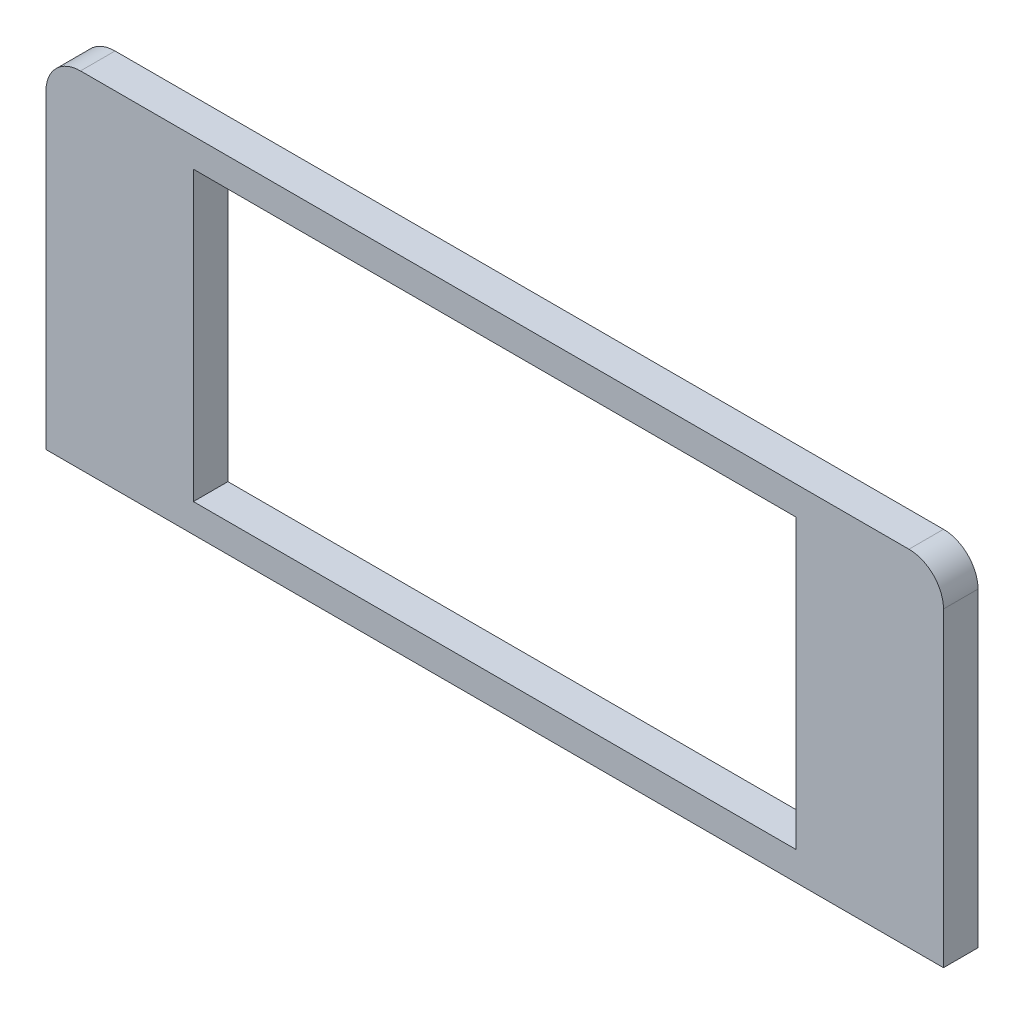
from build123d import *

# Parameters (mm, degrees)
SKETCH1_W           = 130
SKETCH1_H           = 50
BOSS_EXTRUDE1_DEPTH = 5
FILLET1_R           = 5
SKETCH2_W           = 87.3
SKETCH2_H           = 41.7
CUT_EXTRUDE1_DEPTH  = 5


with BuildPart() as part:
    # Sketch1 → Boss-Extrude1 (new body)
    with BuildSketch(Plane.XY):
        Rectangle(SKETCH1_W, SKETCH1_H)
    extrude(amount=BOSS_EXTRUDE1_DEPTH)

    # Fillet1
    fillet1_edges = [part.edges().sort_by_distance(p)[0] for p in [
        (-65, 25, 2.5),
        (65, 25, 2.5),
    ]]
    fillet(fillet1_edges, radius=FILLET1_R)

    # Sketch2 → Cut-Extrude1 (cut)
    with BuildSketch(Plane.XY.offset(5)):
        Rectangle(SKETCH2_W, SKETCH2_H)
    extrude(amount=-CUT_EXTRUDE1_DEPTH, mode=Mode.SUBTRACT)


solid = part.part
